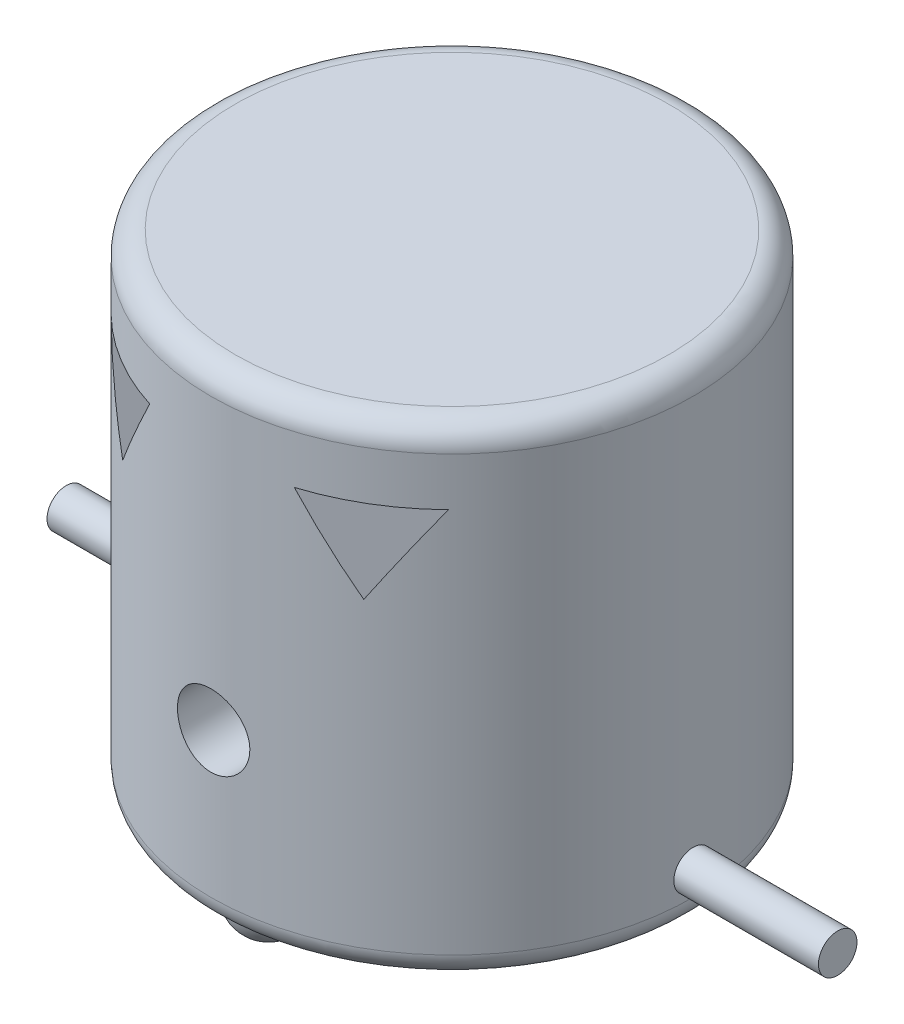
from build123d import *

# Parameters (mm, degrees)
ESQUISSE1_R             = 50
BOSS_EXTRU_1_DEPTH      = 100
ESQUISSE2_R             = 4
BOSS_EXTRU_2_DEPTH      = 30
ESQUISSE3_R             = 4
BOSS_EXTRU_3_DEPTH      = 30
CONG_1_R                = 5
ESQUISSE6_R             = 7.5
ENL_V_MAT_EXTRU_1_DEPTH = 65


with BuildPart() as part:
    # Esquisse1 → Boss.-Extru.1 (new body)
    with BuildSketch(Plane(origin=(0, 0, 0), x_dir=(1, 0, 0), z_dir=(0, 1, 0))):
        Circle(ESQUISSE1_R)
    extrude(amount=BOSS_EXTRU_1_DEPTH)

    # Congé1
    cong_1_edges = [part.edges().sort_by_distance(p)[0] for p in [
        (-50, 0, 0),
        (-50, 100, 0),
    ]]
    fillet(cong_1_edges, radius=CONG_1_R)

    # Esquisse5 → Révolution1 (revolve)
    with BuildSketch(Plane(origin=(0, 0, 0), x_dir=(0, 0, -1), z_dir=(1, 0, 0))):
        with BuildLine():
            Line((-38, 0), (-38, -7.4))
            ThreePointArc((-38, -7.4), (-32.767409819, -5.232590181), (-30.6, 0))
            Line((-30.6, 0), (-38, 0))
        make_face()
    r_volution1 = revolve(axis=Axis((0, 0, 38), (0, -1, 0)))

    # Symétrie4: Révolution1 across plane
    add(r_volution1.mirror(Plane.XY))

    # Esquisse6 → Enlèv. mat.-Extru.1 (cut)
    with BuildSketch(Plane.XY):
        with Locations((0, 35)):
            Circle(ESQUISSE6_R)
        Polygon((-35, 85), (-15, 85), (-25, 67.679491924), align=None)
        Polygon((25, 67.679491924), (35, 85), (15, 85), align=None)
    extrude(amount=ENL_V_MAT_EXTRU_1_DEPTH, mode=Mode.SUBTRACT)


with BuildPart() as body_2:
    # Esquisse2 → Boss.-Extru.2 (new body)
    with BuildSketch(Plane(origin=(50, 0, 0), x_dir=(0, 0, -1), z_dir=(1, 0, 0))):
        with Locations((0, 10)):
            Circle(ESQUISSE2_R)
    extrude(amount=BOSS_EXTRU_2_DEPTH)


with BuildPart() as body_3:
    # Esquisse3 → Boss.-Extru.3 (new body)
    with BuildSketch(Plane.ZY.offset(50)):
        with Locations((0, 10)):
            Circle(ESQUISSE3_R)
    extrude(amount=BOSS_EXTRU_3_DEPTH)


solid = Compound([part.part, body_2.part, body_3.part])
